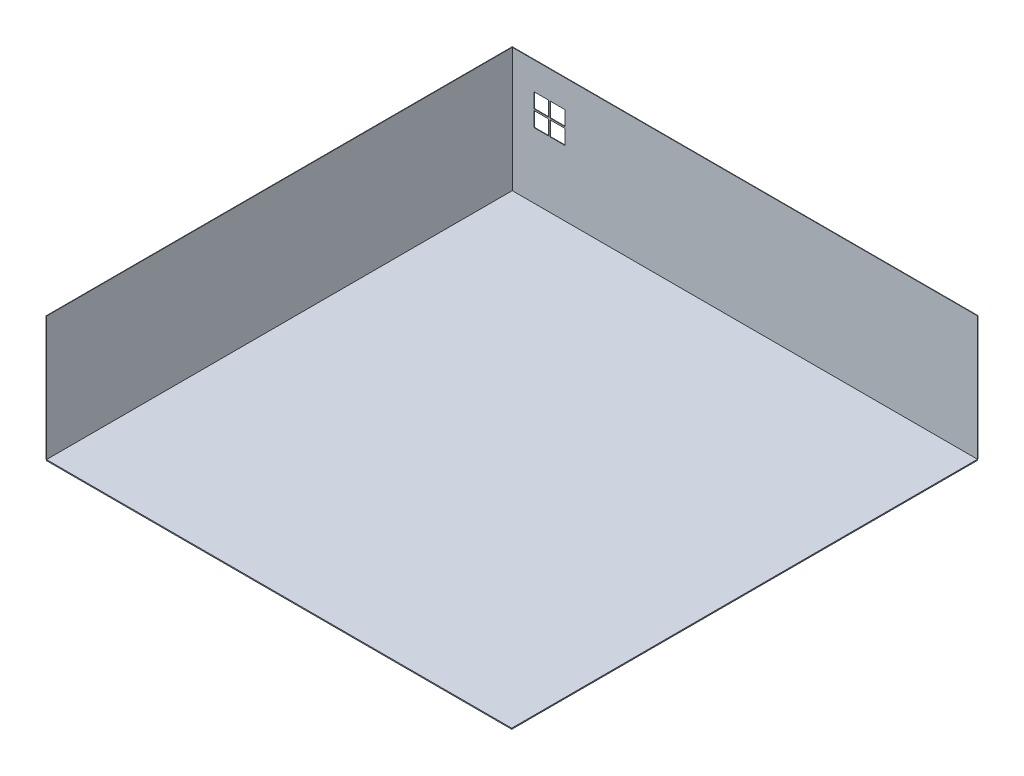
from build123d import *

# Parameters (mm, degrees)
SKETCH1_W           = 10
SKETCH1_H           = 9144
SKETCH1_W_2         = 9144
SKETCH1_H_2         = 10
BOSS_EXTRUDE1_DEPTH = 2438.4
SKETCH3_W           = 289.8
SKETCH3_H           = 289.8
CUT_EXTRUDE1_DEPTH  = 11
SKETCH4_W           = 9134
SKETCH4_H           = 9144
BOSS_EXTRUDE3_DEPTH = 20


with BuildPart() as part:
    # Sketch1 → Boss-Extrude1 (new body)
    with BuildSketch(Plane(origin=(0, 0, 0), x_dir=(1, 0, 0), z_dir=(0, 1, 0))):
        with Locations((-5, 4572)):
            Rectangle(SKETCH1_W, SKETCH1_H)
        with Locations((4562, 9149)):
            Rectangle(SKETCH1_W_2, SKETCH1_H_2)
    extrude(amount=BOSS_EXTRUDE1_DEPTH)

    # Sketch3 → Cut-Extrude1 (cut, through all)
    with BuildSketch(Plane.XY.offset(-9144)):
        with Locations((567.862791314, 1750.309687089)):
            Rectangle(SKETCH3_W, SKETCH3_H)
        with Locations((887.662791314, 1750.309687089)):
            Rectangle(SKETCH3_W, SKETCH3_H)
        with Locations((887.662791314, 1430.509687089)):
            Rectangle(SKETCH3_W, SKETCH3_H)
        with Locations((567.862791314, 1430.509687089)):
            Rectangle(SKETCH3_W, SKETCH3_H)
    extrude(amount=-CUT_EXTRUDE1_DEPTH, mode=Mode.SUBTRACT)


with BuildPart() as body_2:
    # Sketch4 → Boss-Extrude3 (new body)
    with BuildSketch(Plane.XZ):
        with Locations((4567, -4572)):
            Rectangle(SKETCH4_W, SKETCH4_H)
    extrude(amount=BOSS_EXTRUDE3_DEPTH)


solid = Compound([part.part, body_2.part])
